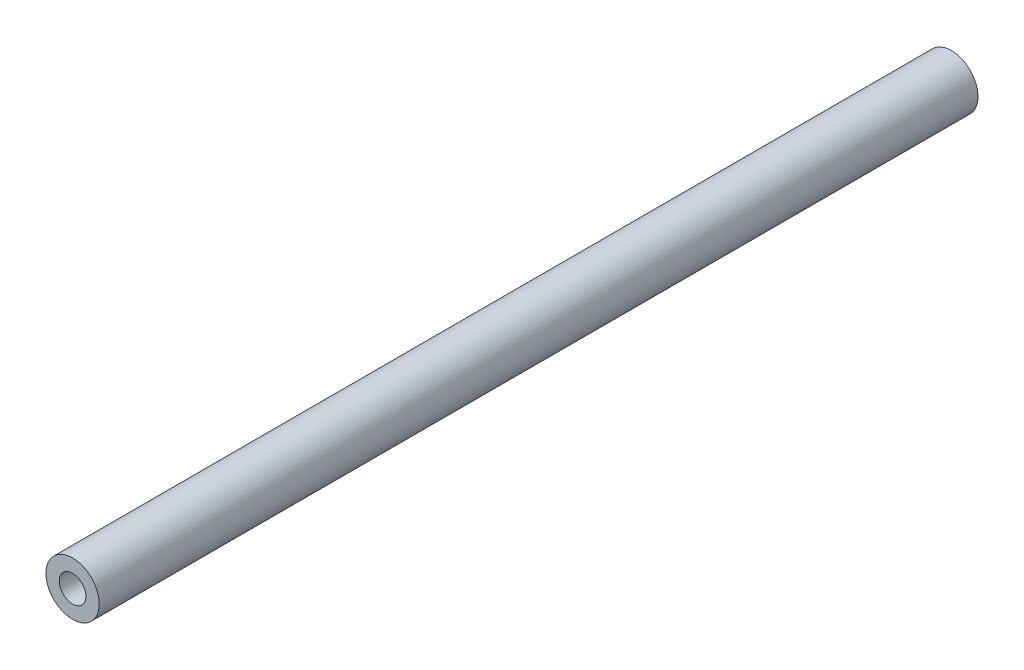
from build123d import *

# Parameters (mm, degrees)
SKETCH1_R           = 6.35
BOSS_EXTRUDE1_DEPTH = 104.775
SKETCH3_R           = 3.175
CUT_EXTRUDE1_DEPTH  = 19.05
SKETCH2_R           = 3.175
CUT_EXTRUDE2_DEPTH  = 19.05


with BuildPart() as part:
    # Sketch1 → Boss-Extrude1 (new body, symmetric)
    with BuildSketch(Plane.XY):
        Circle(SKETCH1_R)
    extrude(amount=BOSS_EXTRUDE1_DEPTH, both=True)

    # Sketch3 → Cut-Extrude1 (cut)
    with BuildSketch(Plane(origin=(0, 0, -104.775), x_dir=(-1, 0, 0), z_dir=(0, 0, -1))):
        Circle(SKETCH3_R)
    extrude(amount=-CUT_EXTRUDE1_DEPTH, mode=Mode.SUBTRACT)

    # Sketch2 → Cut-Extrude2 (cut)
    with BuildSketch(Plane.XY.offset(104.775)):
        Circle(SKETCH2_R)
    extrude(amount=-CUT_EXTRUDE2_DEPTH, mode=Mode.SUBTRACT)


solid = part.part
